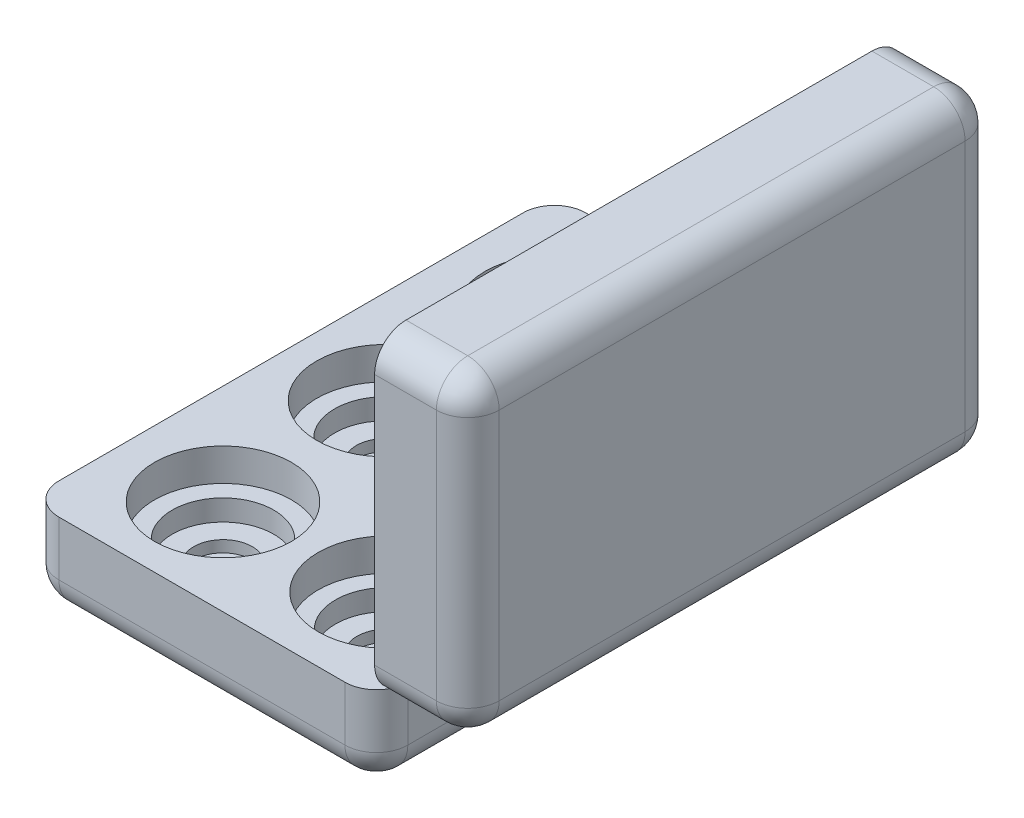
from build123d import *

# Parameters (mm, degrees)
SKETCH1_W           = 84.650892634
SKETCH1_H           = 127.841891795
SKETCH1_R           = 16.706017138
SKETCH1_R_2         = 16.621238302
BOSS_EXTRUDE3_DEPTH = 20.828
SKETCH3_W           = 84.650892634
SKETCH3_H           = 127.841891795
BOSS_EXTRUDE4_DEPTH = 12.954
SKETCH4_R           = 12.540814035
SKETCH4_R_2         = 12.526296714
SKETCH4_R_3         = 12.564707055
SKETCH4_R_4         = 12.325039909
SKETCH4_R_5         = 12.332395729
SKETCH4_R_6         = 12.512513451
CUT_EXTRUDE1_DEPTH  = 5.08
SKETCH5_R           = 7.17451022
SKETCH5_R_2         = 7.161633978
SKETCH5_R_3         = 7.051719989
SKETCH5_R_4         = 7.07658049
SKETCH5_R_5         = 7.105219729
SKETCH5_R_6         = 7.335853032
CUT_EXTRUDE2_DEPTH  = 2.794
FILLET4_R           = 7.62
FILLET5_R           = 7.62
SKETCH6_W           = 128.278670116
SKETCH6_H           = 76.323901273
BOSS_EXTRUDE5_DEPTH = 22.606
FILLET6_R           = 7.62
SHELL1_T            = -2.54


with BuildPart() as part:
    # Sketch1 → Boss-Extrude3 (new body)
    with BuildSketch(Plane(origin=(0, 0, 0), x_dir=(1, 0, 0), z_dir=(0, 1, 0))):
        with Locations((-2.878129168, -11.163832012)):
            Rectangle(SKETCH1_W, SKETCH1_H)
        with Locations((-22.431698426, -11.000478916)):
            Circle(SKETCH1_R, mode=Mode.SUBTRACT)
        with Locations((17.993817947, -51.035012313)):
            Circle(SKETCH1_R, mode=Mode.SUBTRACT)
        with Locations((-20.875024015, -51.987506281)):
            Circle(SKETCH1_R_2, mode=Mode.SUBTRACT)
        with Locations((17.457163136, 28.74766961)):
            Circle(SKETCH1_R, mode=Mode.SUBTRACT)
        with Locations((17.81493301, -10.60701654)):
            Circle(SKETCH1_R, mode=Mode.SUBTRACT)
        with Locations((-20.824213392, 28.211014799)):
            Circle(SKETCH1_R, mode=Mode.SUBTRACT)
    extrude(amount=BOSS_EXTRUDE3_DEPTH)

    # Sketch3 → Boss-Extrude4 (add)
    with BuildSketch(Plane.XZ):
        with Locations((-2.878129168, 11.163832012)):
            Rectangle(SKETCH3_W, SKETCH3_H)
    extrude(amount=-BOSS_EXTRUDE4_DEPTH)

    # Sketch4 → Cut-Extrude1 (cut)
    with BuildSketch(Plane(origin=(0, 12.954, 0), x_dir=(1, 0, 0), z_dir=(0, 1, 0))):
        with Locations((17.81493301, -10.60701654)):
            Circle(SKETCH4_R)
        with Locations((17.457163136, 28.74766961)):
            Circle(SKETCH4_R_2)
        with Locations((-20.824213392, 28.211014799)):
            Circle(SKETCH4_R_3)
        with Locations((-20.875024015, -51.987506281)):
            Circle(SKETCH4_R_4)
        with Locations((-22.431698426, -11.000478916)):
            Circle(SKETCH4_R_5)
        with Locations((17.993817947, -51.035012313)):
            Circle(SKETCH4_R_6)
    extrude(amount=-CUT_EXTRUDE1_DEPTH, mode=Mode.SUBTRACT)

    # Sketch5 → Cut-Extrude2 (cut)
    with BuildSketch(Plane(origin=(0, 7.874, 0), x_dir=(1, 0, 0), z_dir=(0, 1, 0))):
        with Locations((-20.824213392, 28.211014799)):
            Circle(SKETCH5_R)
        with Locations((17.81493301, -10.60701654)):
            Circle(SKETCH5_R_2)
        with Locations((17.457163136, 28.74766961)):
            Circle(SKETCH5_R_3)
        with Locations((-22.431698426, -11.000478916)):
            Circle(SKETCH5_R_4)
        with Locations((-20.875024015, -51.987506281)):
            Circle(SKETCH5_R_5)
        with Locations((17.993817947, -51.035012313)):
            Circle(SKETCH5_R_6)
    extrude(amount=-CUT_EXTRUDE2_DEPTH, mode=Mode.SUBTRACT)

    # Fillet4
    fillet4_edges = [part.edges().sort_by_distance(p)[0] for p in [
        (-45.203575485, 10.414, -52.757113885),
        (-45.203575485, 10.414, 75.08477791),
        (39.447317149, 10.414, 75.08477791),
        (39.447317149, 10.414, -52.757113885),
    ]]
    fillet(fillet4_edges, radius=FILLET4_R)

    # Fillet5
    fillet5_edges = [part.edges().sort_by_distance(p)[0] for p in [
        (-2.878129168, 0, -52.757113885),
        (39.447317149, 0, 11.163832012),
        (-2.878129168, 0, 75.08477791),
        (-45.203575485, 0, 11.163832012),
        (37.215470822, 0, 72.852931583),
        (-42.971729158, 0, 72.852931583),
        (-42.971729158, 0, -50.525267558),
        (37.215470822, 0, -50.525267558),
    ]]
    fillet(fillet5_edges, radius=FILLET5_R)


with BuildPart() as body_2:
    # Sketch6 → Boss-Extrude5 (new body)
    with BuildSketch(Plane(origin=(39.447317149, 0, 0), x_dir=(0, 0, -1), z_dir=(1, 0, 0))):
        with Locations((-11.382221173, 58.989950637)):
            Rectangle(SKETCH6_W, SKETCH6_H)
    extrude(amount=BOSS_EXTRUDE5_DEPTH)

    # Fillet6
    fillet6_edges = [body_2.edges().sort_by_distance(p)[0] for p in [
        (62.053317149, 58.989950637, 75.521556231),
        (62.053317149, 20.828, 11.382221173),
        (62.053317149, 58.989950637, -52.757113885),
        (50.750317149, 20.828, -52.757113885),
        (50.750317149, 20.828, 75.521556231),
        (50.750317149, 97.151901273, 75.521556231),
        (50.750317149, 97.151901273, -52.757113885),
        (62.053317149, 97.151901273, 11.382221173),
    ]]
    fillet(fillet6_edges, radius=FILLET6_R)

    # Shell1
    shell1_openings = [body_2.faces().sort_by_distance(p)[0] for p in [
        (39.447317149, 58.989950637, 11.382221173),
    ]]
    offset(amount=SHELL1_T, openings=shell1_openings, kind=Kind.INTERSECTION)


solid = Compound([part.part, body_2.part])
